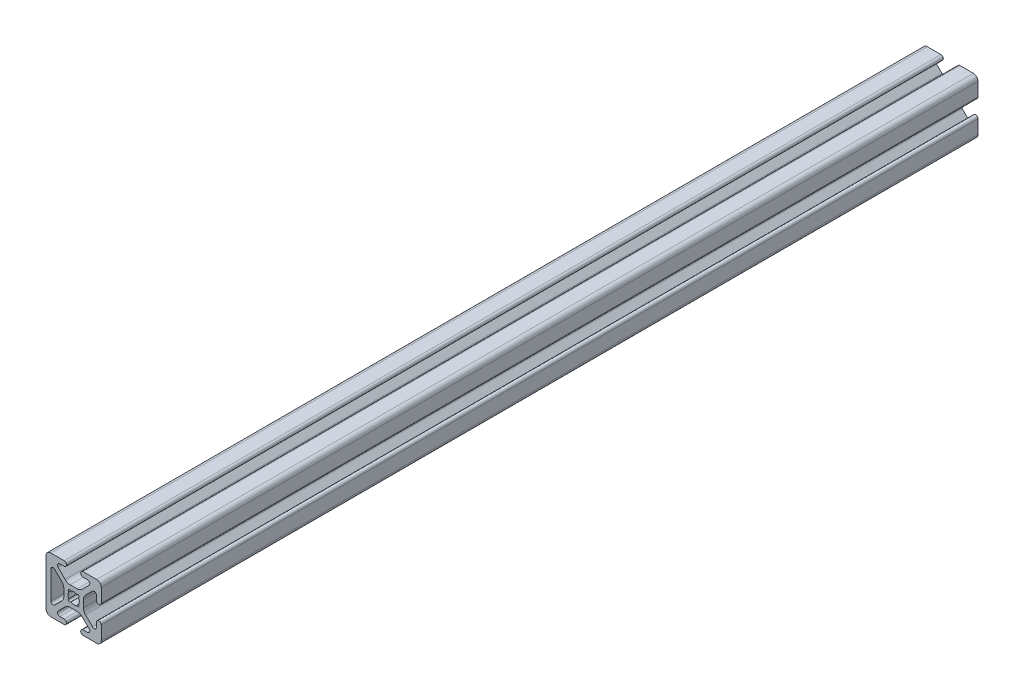
from build123d import *

# Parameters (mm, degrees)
BOSS_EXTRUDE1_DEPTH = 403


with BuildPart() as part:
    # Sketch1 → Boss-Extrude1 (new body)
    with BuildSketch(Plane.XY.offset(12.7)):
        with BuildLine():
            Line((-12.7, 10.5918), (-12.7, -10.5918))
            ThreePointArc((-12.7, -10.5918), (-12.082522516, -12.082522516), (-10.5918, -12.7))
            Line((-10.5918, -12.7), (-4.3561, -12.7))
            ThreePointArc((-4.3561, -12.7), (-3.2512, -11.5951), (-4.3561, -10.4902))
            Line((-4.3561, -10.4902), (-6.370083784, -10.4902))
            ThreePointArc((-6.370083784, -10.4902), (-7.34885674, -9.836204819), (-7.119204173, -8.681663397))
            Line((-7.119204173, -8.681663397), (-3.884643888, -5.447103113))
            ThreePointArc((-3.884643888, -5.447103113), (-2.854599756, -4.758849627), (-1.639579858, -4.517167143))
            Line((-1.639579858, -4.517167143), (1.639579858, -4.517167143))
            ThreePointArc((1.639579858, -4.517167143), (2.854599756, -4.758849627), (3.884643888, -5.447103113))
            Line((3.884643888, -5.447103113), (7.119204173, -8.681663397))
            ThreePointArc((7.119204173, -8.681663397), (7.34885674, -9.836204819), (6.370083784, -10.4902))
            Line((6.370083784, -10.4902), (4.356099789, -10.4902))
            ThreePointArc((4.356099789, -10.4902), (3.251199789, -11.5951), (4.356099789, -12.7))
            Line((4.356099789, -12.7), (10.5918, -12.7))
            ThreePointArc((10.5918, -12.7), (12.082522516, -12.082522516), (12.7, -10.5918))
            Line((12.7, -10.5918), (12.7, -4.3561))
            ThreePointArc((12.7, -4.3561), (11.5951, -3.2512), (10.4902, -4.3561))
            Line((10.4902, -4.3561), (10.4902, -6.370083784))
            ThreePointArc((10.4902, -6.370083784), (9.836204819, -7.34885674), (8.681663397, -7.119204173))
            Line((8.681663397, -7.119204173), (5.447103113, -3.884643888))
            ThreePointArc((5.447103113, -3.884643888), (4.758849627, -2.854599756), (4.517167143, -1.639579858))
            Line((4.517167143, -1.639579858), (4.517167143, 1.639579858))
            ThreePointArc((4.517167143, 1.639579858), (4.758849627, 2.854599756), (5.447103113, 3.884643888))
            Line((5.447103113, 3.884643888), (8.681663397, 7.119204173))
            ThreePointArc((8.681663397, 7.119204173), (9.836204819, 7.34885674), (10.4902, 6.370083784))
            Line((10.4902, 6.370083784), (10.4902, 4.3561))
            ThreePointArc((10.4902, 4.3561), (11.5951, 3.2512), (12.7, 4.3561))
            Line((12.7, 4.3561), (12.7, 10.5918))
            ThreePointArc((12.7, 10.5918), (12.082522516, 12.082522516), (10.5918, 12.7))
            Line((10.5918, 12.7), (4.3561, 12.7))
            ThreePointArc((4.3561, 12.7), (3.2512, 11.5951), (4.3561, 10.4902))
            Line((4.3561, 10.4902), (6.370083784, 10.4902))
            ThreePointArc((6.370083784, 10.4902), (7.34885674, 9.836204819), (7.119204173, 8.681663397))
            Line((7.119204173, 8.681663397), (3.884643888, 5.447103113))
            ThreePointArc((3.884643888, 5.447103113), (2.854599756, 4.758849627), (1.639579858, 4.517167143))
            Line((1.639579858, 4.517167143), (-1.639579858, 4.517167143))
            ThreePointArc((-1.639579858, 4.517167143), (-2.854599756, 4.758849627), (-3.884643888, 5.447103113))
            Line((-3.884643888, 5.447103113), (-7.119204173, 8.681663397))
            ThreePointArc((-7.119204173, 8.681663397), (-7.34885674, 9.836204819), (-6.370083784, 10.4902))
            Line((-6.370083784, 10.4902), (-4.356099789, 10.4902))
            ThreePointArc((-4.356099789, 10.4902), (-3.251199789, 11.5951), (-4.356099789, 12.7))
            Line((-4.356099789, 12.7), (-10.5918, 12.7))
            ThreePointArc((-10.5918, 12.7), (-12.082522516, 12.082522516), (-12.7, 10.5918))
        make_face()
        with BuildLine():
            Line((-8.681663397, 7.119204173), (-5.447103113, 3.884643888))
            ThreePointArc((-5.447103113, 3.884643888), (-4.758849627, 2.854599756), (-4.517167143, 1.639579858))
            Line((-4.517167143, 1.639579858), (-4.517167143, -1.639579858))
            ThreePointArc((-4.517167143, -1.639579858), (-4.758849627, -2.854599756), (-5.447103113, -3.884643888))
            Line((-5.447103113, -3.884643888), (-8.681663397, -7.119204173))
            ThreePointArc((-8.681663397, -7.119204173), (-9.836204819, -7.34885674), (-10.4902, -6.370083784))
            Line((-10.4902, -6.370083784), (-10.4902, 6.370083784))
            ThreePointArc((-10.4902, 6.370083784), (-9.836204819, 7.34885674), (-8.681663397, 7.119204173))
        make_face(mode=Mode.SUBTRACT)
        with BuildLine():
            ThreePointArc((-2.231856261, 1.340533427), (-2.28996531, 2.28996531), (-1.340533427, 2.231856261))
            ThreePointArc((-1.340533427, 2.231856261), (-1.1e-08, 2.603499998), (1.340533408, 2.231856273))
            ThreePointArc((1.340533408, 2.231856273), (2.28996531, 2.28996533), (2.231856262, 1.340533427))
            ThreePointArc((2.231856262, 1.340533427), (2.603499999, 1.1e-08), (2.231856274, -1.340533408))
            ThreePointArc((2.231856274, -1.340533408), (2.289965331, -2.28996531), (1.340533428, -2.231856262))
            ThreePointArc((1.340533428, -2.231856262), (6e-09, -2.603499999), (-1.340533417, -2.231856268))
            ThreePointArc((-1.340533417, -2.231856268), (-2.28996532, -2.28996532), (-2.231856267, -1.340533417))
            ThreePointArc((-2.231856267, -1.340533417), (-2.603499998, 6e-09), (-2.231856261, 1.340533427))
        make_face(mode=Mode.SUBTRACT)
    extrude(amount=-BOSS_EXTRUDE1_DEPTH)

    # Sketch5 → 1/4-20 Tapped Hole1 (revolve, cut)
    with BuildSketch(Plane(origin=(0, 4.517167143, -40.35), x_dir=(0, 0, 1), z_dir=(1, 0, 0))):
        Polygon((0, 0), (0, 18.749984045), (2.5527, 17.216167143), (2.5527, 0), align=None)
    revolve(axis=Axis((0, 10.867167143, -40.35), (0, -1, 0)), mode=Mode.SUBTRACT)


solid = part.part
